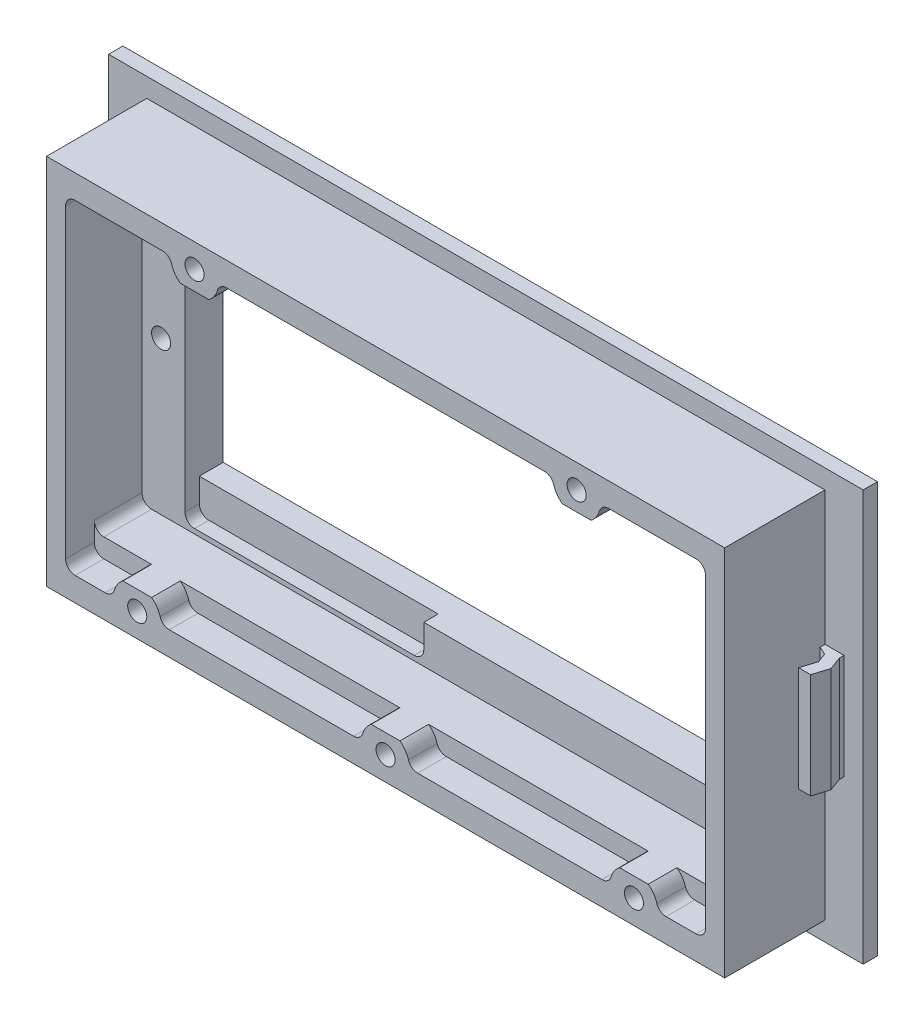
from build123d import *

# Parameters (mm, degrees)
SKETCH_1_W          = 79
SKETCH_1_H          = 43
EXTRUDE_1_DEPTH     = 1.5
SKETCH_2_W          = 71
SKETCH_2_H          = 39
EXTRUDE_2_DEPTH     = 10.5
SKETCH_3_W          = 67
SKETCH_3_H          = 30
CUT_EXTRUDE_1_DEPTH = 8
SKETCH_4_W          = 58
SKETCH_4_H          = 23
CUT_EXTRUDE_2_DEPTH = 5
SKETCH_6_R          = 1
CUT_EXTRUDE_3_DEPTH = 9
CUT_EXTRUDE_3_TAPER = 4
SKETCH_7_R          = 1
CUT_EXTRUDE_4_DEPTH = 3
CUT_EXTRUDE_4_TAPER = 4
CUT_EXTRUDE_5_DEPTH = 3
FILLET_1_R          = 1
SKETCH_9_W          = 25
SKETCH_9_H          = 3.5
CUT_EXTRUDE_6_DEPTH = 1.5
FILLET_2_R          = 1
EXTRUDE_3_DEPTH     = 5.5


with BuildPart() as part:
    # Эскиз1 → Бобышка-Вытянуть1 (new body)
    with BuildSketch(Plane.XY):
        Rectangle(SKETCH_1_W, SKETCH_1_H)
    extrude(amount=EXTRUDE_1_DEPTH)

    # Эскиз2 → Бобышка-Вытянуть2 (add)
    with BuildSketch(Plane.XY.offset(1.5)):
        Rectangle(SKETCH_2_W, SKETCH_2_H)
    extrude(amount=EXTRUDE_2_DEPTH)

    # Эскиз3 → Вырез-Вытянуть1 (cut)
    with BuildSketch(Plane.XY.offset(12)):
        Rectangle(SKETCH_3_W, SKETCH_3_H)
    extrude(amount=-CUT_EXTRUDE_1_DEPTH, mode=Mode.SUBTRACT)

    # Эскиз4 → Вырез-Вытянуть2 (cut, through all)
    with BuildSketch(Plane.XY.offset(4)):
        with Locations((0, 0.5)):
            Rectangle(SKETCH_4_W, SKETCH_4_H)
    extrude(amount=-CUT_EXTRUDE_2_DEPTH, mode=Mode.SUBTRACT)

    # Эскиз6 → Вырез-Вытянуть3 (cut)
    with BuildSketch(Plane.XY.offset(12)):
        with Locations((-26, -17)):
            Circle(SKETCH_6_R)
        with Locations((0, -17)):
            Circle(SKETCH_6_R)
        with Locations((26, -17)):
            Circle(SKETCH_6_R)
        with Locations((20, 17)):
            Circle(SKETCH_6_R)
        with Locations((-20, 17)):
            Circle(SKETCH_6_R)
    extrude(amount=-CUT_EXTRUDE_3_DEPTH, taper=CUT_EXTRUDE_3_TAPER, mode=Mode.SUBTRACT)

    # Эскиз7 → Вырез-Вытянуть4 (cut)
    with BuildSketch(Plane.XY.offset(4)):
        with Locations((-31.5, 1)):
            Circle(SKETCH_7_R)
    cut_extrude_4 = extrude(amount=-CUT_EXTRUDE_4_DEPTH, taper=CUT_EXTRUDE_4_TAPER, mode=Mode.SUBTRACT)

    # Зеркальное отражение1: Вырез-Вытянуть4 across plane
    add(cut_extrude_4.mirror(Plane(origin=(0, 0, 0), x_dir=(0, 0, 1), z_dir=(1, 0, 0))), mode=Mode.SUBTRACT)

    # Эскиз8 → Вырез-Вытянуть5 (cut)
    with BuildSketch(Plane.XY.offset(12)):
        with BuildLine():
            Line((-17.5, 17), (17.5, 17))
            ThreePointArc((17.5, 17), (20, 14.5), (22.5, 17))
            Line((22.5, 17), (33.5, 17))
            Line((33.5, 17), (33.5, 15))
            Line((33.5, 15), (33.5, -15))
            Line((33.5, -15), (33.5, -17))
            Line((33.5, -17), (28.5, -17))
            ThreePointArc((28.5, -17), (26, -14.5), (23.5, -17))
            Line((23.5, -17), (2.5, -17))
            ThreePointArc((2.5, -17), (0, -14.5), (-2.5, -17))
            Line((-2.5, -17), (-23.5, -17))
            ThreePointArc((-23.5, -17), (-26, -14.5), (-28.5, -17))
            Line((-28.5, -17), (-33.5, -17))
            Line((-33.5, -17), (-33.5, -15))
            Line((-33.5, -15), (-33.5, 15))
            Line((-33.5, 15), (-33.5, 17))
            Line((-33.5, 17), (-22.5, 17))
            ThreePointArc((-22.5, 17), (-20, 14.5), (-17.5, 17))
        make_face()
    extrude(amount=-CUT_EXTRUDE_5_DEPTH, mode=Mode.SUBTRACT)

    # Скругление1
    fillet_1_edges = [part.edges().sort_by_distance(p)[0] for p in [
        (28.5, -17, 10.5),
        (2.5, -17, 10.5),
        (-23.5, -17, 10.5),
        (-33.5, -17, 10.5),
        (-22.5, 17, 10.5),
        (-17.5, 17, 10.5),
        (17.5, 17, 10.5),
        (22.5, 17, 10.5),
        (33.5, 17, 10.5),
        (33.5, -17, 10.5),
        (23.5, -17, 10.5),
        (-2.5, -17, 10.5),
        (-28.5, -17, 10.5),
        (-33.5, 17, 10.5),
        (-33.5, 15, 6.5),
        (33.5, 15, 6.5),
        (33.5, -15, 6.5),
        (-33.5, -15, 6.5),
    ]]
    fillet(fillet_1_edges, radius=FILLET_1_R)

    # Эскиз9 → Вырез-Вытянуть6 (cut)
    with BuildSketch(Plane.XY.offset(4)):
        with Locations((-16.5, -12.75)):
            Rectangle(SKETCH_9_W, SKETCH_9_H)
    extrude(amount=-CUT_EXTRUDE_6_DEPTH, mode=Mode.SUBTRACT)

    # Скругление2
    fillet_2_edges = [part.edges().sort_by_distance(p)[0] for p in [
        (-29, -14.5, 3.25),
        (-4, -14.5, 3.25),
    ]]
    fillet(fillet_2_edges, radius=FILLET_2_R)

    # Эскиз14 → Бобышка-Вытянуть3 (add, symmetric)
    with BuildSketch(Plane(origin=(0, 0, 0), x_dir=(1, 0, 0), z_dir=(0, 1, 0))):
        Polygon((-35.5, -1.5), (-37.5, -1.5), (-37.5, -2), (-38, -3.37373871), (-37.5, -5), (-36.245480955, -4.997017038), (-36.734683372, -3.405875127), (-36.372368855, -2.410424172), (-35.5, -2), align=None)
    extrude_3 = extrude(amount=EXTRUDE_3_DEPTH, both=True)

    # Зеркальное отражение2: Бобышка-Вытянуть3 across plane
    add(extrude_3.mirror(Plane(origin=(0, 0, 0), x_dir=(0, 0, 1), z_dir=(1, 0, 0))))


solid = part.part
